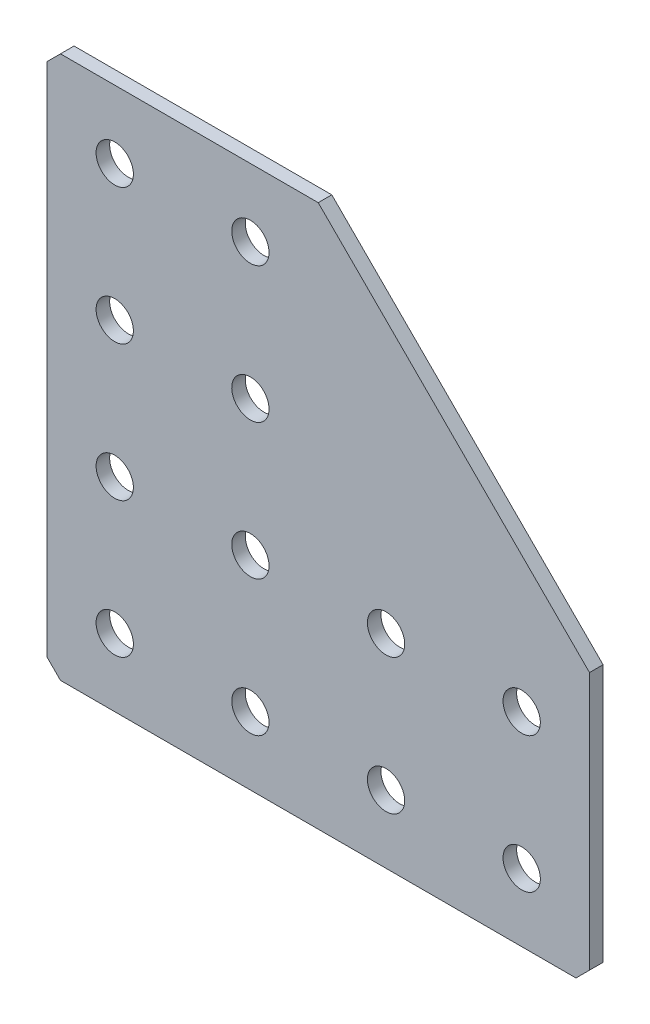
from build123d import *

# Parameters (mm, degrees)
EXTRUDE_1_DEPTH   = 2
HOLE_WIZARD_M51_D = 5.5
CHAMFER_1_SIZE    = 2


with BuildPart() as part:
    # Эскиз1 → Бобышка-Вытянуть1 (new body)
    with BuildSketch(Plane(origin=(0, 0, 0), x_dir=(1, 0, 0), z_dir=(0, 0, -1))):
        Polygon((0, 0), (0, 80), (80, 80), (80, 40), (40, 0), align=None)
    extrude(amount=EXTRUDE_1_DEPTH)

    # Отверстие с зазором M51 (through all)
    with Locations(Plane(origin=(0, 0, -2), x_dir=(1, 0, 0), z_dir=(0, 0, -1))):
        with Locations((10, 70), (10, 50), (10, 30), (10, 10), (30, 70), (30, 50), (30, 30), (30, 10), (50, 70), (50, 50), (70, 70), (70, 50)):
            Hole(HOLE_WIZARD_M51_D / 2)

    # Фаска1
    chamfer_1_edges = [part.edges().sort_by_distance(p)[0] for p in [
        (0, 0, -1),
        (0, -80, -1),
        (80, -80, -1),
    ]]
    chamfer(chamfer_1_edges, length=CHAMFER_1_SIZE)


solid = part.part
